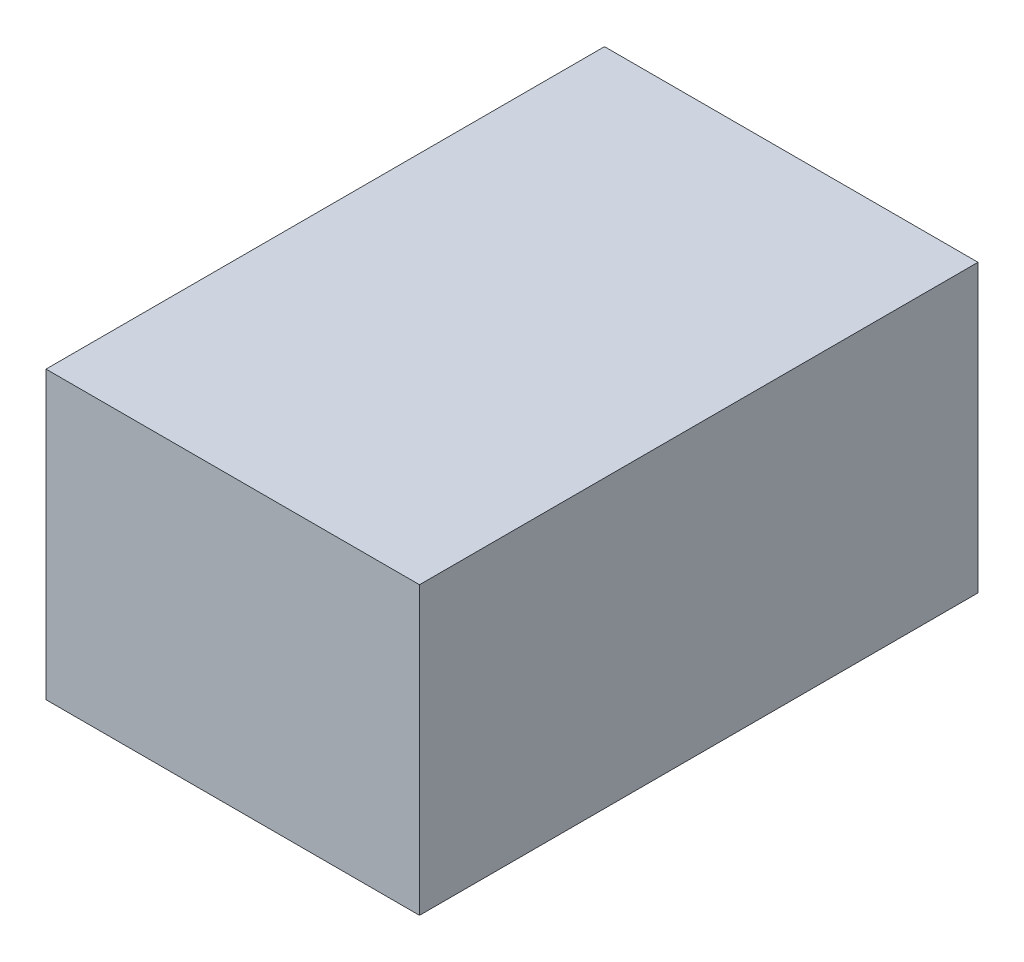
from build123d import *

# Parameters (mm, degrees)
SKETCH1_W           = 30
SKETCH1_H           = 23
BOSS_EXTRUDE1_DEPTH = 44.86


with BuildPart() as part:
    # Sketch1 → Boss-Extrude1 (new body)
    with BuildSketch(Plane.XY):
        with Locations((7.8, -29.136725871)):
            Rectangle(SKETCH1_W, SKETCH1_H)
    extrude(amount=BOSS_EXTRUDE1_DEPTH)


solid = part.part
